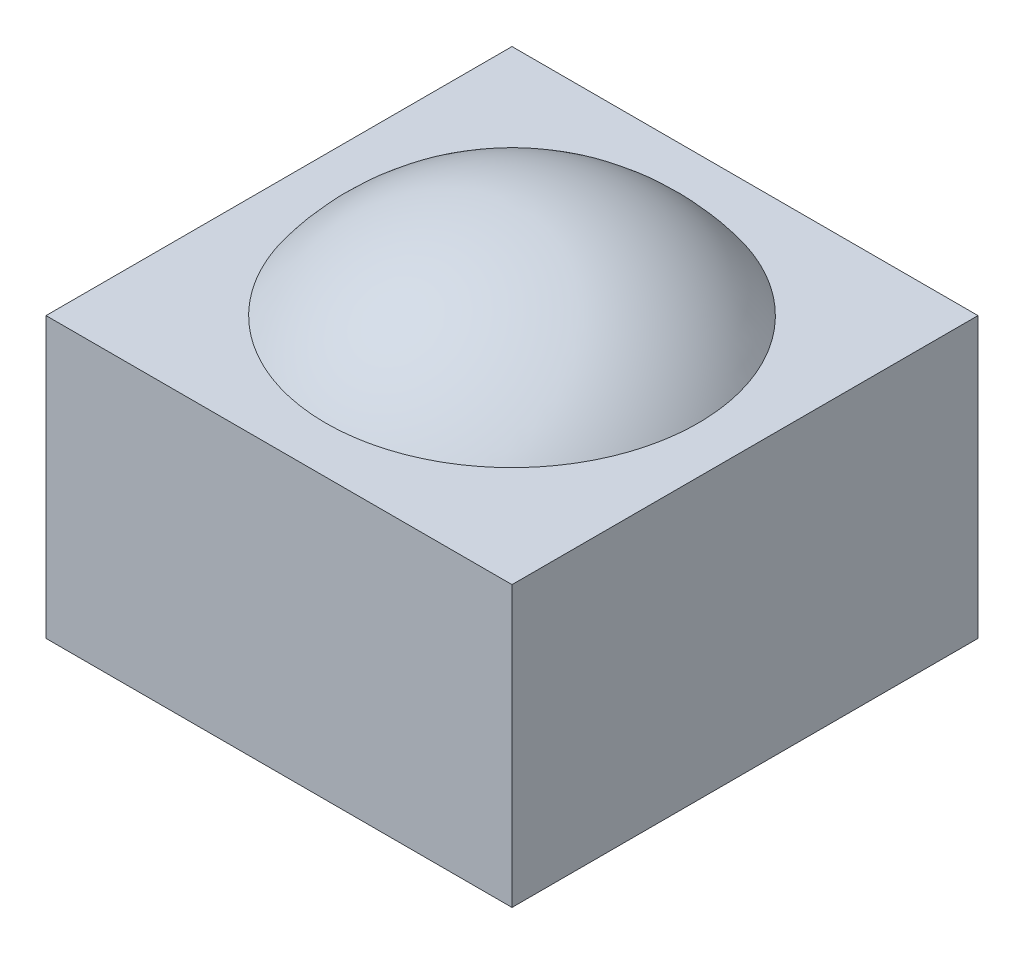
from build123d import *

# Parameters (mm, degrees)
SKIZZE2_W                       = 50
SKIZZE2_H                       = 50
AUFSATZ_LINEAR_AUSTRAGEN1_DEPTH = 15


with BuildPart() as part:
    # Skizze1 → Rotation1 (revolve)
    with BuildSketch(Plane.XY):
        with BuildLine():
            Line((0, 0), (0, 25))
            ThreePointArc((0, 25), (-25, 0), (0, -25))
            Line((0, -25), (0, 0))
        make_face()
    revolve(axis=Axis((0, 0, 0), (0, 1, 0)))


with BuildPart() as body_2:
    # Skizze2 → Aufsatz-Linear austragen1 (new body, symmetric)
    with BuildSketch(Plane(origin=(0, 0, 0), x_dir=(1, 0, 0), z_dir=(0, 1, 0))):
        Rectangle(SKIZZE2_W, SKIZZE2_H)
    extrude(amount=AUFSATZ_LINEAR_AUSTRAGEN1_DEPTH, both=True)


solid = Compound([part.part, body_2.part])
